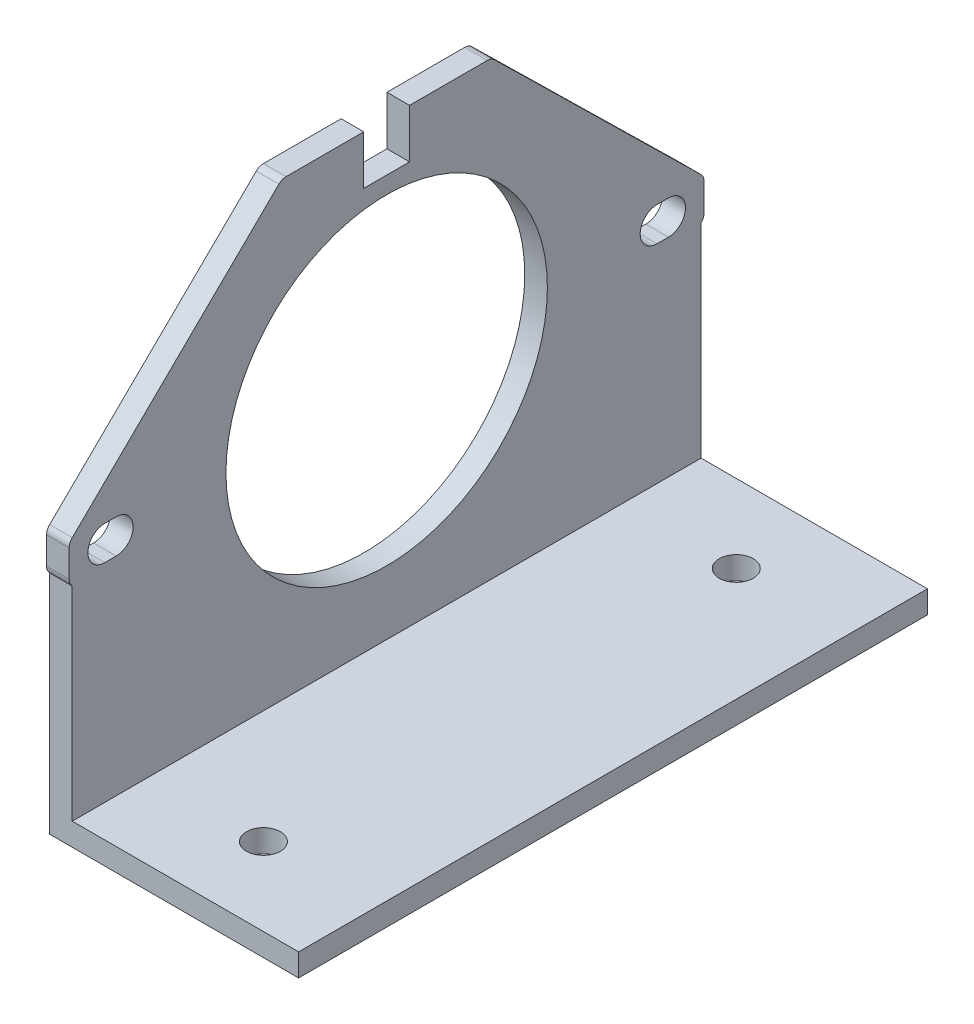
from build123d import *

# Parameters (mm, degrees)
SKETCH1_R           = 14.2
SKETCH1_W           = 4.4
SKETCH1_H           = 4.2
BOSS_EXTRUDE1_DEPTH = 2
BOSS_EXTRUDE2_DEPTH = 2
SKETCH3_W           = 55.560809748
SKETCH3_H           = 2
BOSS_EXTRUDE3_DEPTH = 20
CUT_EXTRUDE1_DEPTH  = 2


with BuildPart() as part:
    # Sketch1 → Boss-Extrude1 (new body)
    with BuildSketch(Plane(origin=(668.139739498, 0, 0), x_dir=(0, 0, -1), z_dir=(1, 0, 0))):
        with BuildLine():
            ThreePointArc((-1314.332175016, 878.774707493), (-1314.042285701, 878.583942821), (-1313.701770142, 878.517038946))
            Line((-1313.701770142, 878.517038946), (-1306.83550516, 878.517038946))
            Line((-1306.83550516, 878.517038946), (-1306.83550516, 882.842038946))
            Line((-1306.83550516, 882.842038946), (-1302.78550516, 882.842038946))
            Line((-1302.78550516, 882.842038946), (-1302.78550516, 878.517038946))
            Line((-1302.78550516, 878.517038946), (-1295.919240178, 878.517038946))
            ThreePointArc((-1295.919240178, 878.517038946), (-1295.578724618, 878.583942821), (-1295.288835304, 878.774707493))
            Line((-1295.288835304, 878.774707493), (-1277.030100286, 896.694420906))
            ThreePointArc((-1277.030100286, 896.694420906), (-1276.830636379, 896.988445301), (-1276.76050516, 897.336752359))
            Line((-1276.76050516, 897.336752359), (-1276.76050516, 899.747325533))
            ThreePointArc((-1276.76050516, 899.747325533), (-1276.830636379, 900.095632591), (-1277.030100286, 900.389656986))
            Line((-1277.030100286, 900.389656986), (-1295.288835304, 918.309370399))
            ThreePointArc((-1295.288835304, 918.309370399), (-1295.578724618, 918.500135071), (-1295.919240178, 918.567038946))
            Line((-1295.919240178, 918.567038946), (-1302.78550516, 918.567038946))
            Line((-1302.78550516, 918.567038946), (-1302.78550516, 914.242038946))
            Line((-1302.78550516, 914.242038946), (-1306.83550516, 914.242038946))
            Line((-1306.83550516, 914.242038946), (-1306.83550516, 918.567038946))
            Line((-1306.83550516, 918.567038946), (-1313.701770142, 918.567038946))
            ThreePointArc((-1313.701770142, 918.567038946), (-1314.042285701, 918.500135071), (-1314.332175016, 918.309370399))
            Line((-1314.332175016, 918.309370399), (-1332.590910034, 900.389656986))
            ThreePointArc((-1332.590910034, 900.389656986), (-1332.79037394, 900.095632591), (-1332.86050516, 899.747325533))
            Line((-1332.86050516, 899.747325533), (-1332.86050516, 897.336752359))
            ThreePointArc((-1332.86050516, 897.336752359), (-1332.79037394, 896.988445301), (-1332.590910034, 896.694420906))
            Line((-1332.590910034, 896.694420906), (-1314.332175016, 878.774707493))
        make_face()
        with Locations((-1304.81050516, 898.542038946)):
            Circle(SKETCH1_R, mode=Mode.SUBTRACT)
        with BuildLine():
            Line((-1329.71050516, 900.042038946), (-1328.71050516, 900.042038946))
            ThreePointArc((-1328.71050516, 900.042038946), (-1327.21050516, 898.542038946), (-1328.71050516, 897.042038946))
            Line((-1328.71050516, 897.042038946), (-1329.71050516, 897.042038946))
            ThreePointArc((-1329.71050516, 897.042038946), (-1330.771165332, 897.481378774), (-1331.21050516, 898.542038946))
            ThreePointArc((-1331.21050516, 898.542038946), (-1330.771165332, 899.602699118), (-1329.71050516, 900.042038946))
        make_face(mode=Mode.SUBTRACT)
        with BuildLine():
            ThreePointArc((-1279.91050516, 900.042038946), (-1278.41050516, 898.542038946), (-1279.91050516, 897.042038946))
            Line((-1279.91050516, 897.042038946), (-1280.91050516, 897.042038946))
            ThreePointArc((-1280.91050516, 897.042038946), (-1281.971165332, 897.481378774), (-1282.41050516, 898.542038946))
            ThreePointArc((-1282.41050516, 898.542038946), (-1281.971165332, 899.602699118), (-1280.91050516, 900.042038946))
            Line((-1280.91050516, 900.042038946), (-1279.91050516, 900.042038946))
        make_face(mode=Mode.SUBTRACT)
        with Locations((-1286.76050516, 898.542038946)):
            Rectangle(SKETCH1_W, SKETCH1_H, mode=Mode.SUBTRACT)
        with Locations((-1322.86050516, 898.542038946)):
            Rectangle(SKETCH1_W, SKETCH1_H, mode=Mode.SUBTRACT)
        with Locations((-1322.86050516, 898.542038946)):
            Rectangle(SKETCH1_W, SKETCH1_H)
        with Locations((-1286.76050516, 898.542038946)):
            Rectangle(SKETCH1_W, SKETCH1_H)
    extrude(amount=BOSS_EXTRUDE1_DEPTH)

    # Sketch2 → Boss-Extrude2 (add)
    with BuildSketch(Plane(origin=(670.139739498, 0, 0), x_dir=(0, 0, -1), z_dir=(1, 0, 0))):
        with BuildLine():
            Line((-1332.590910034, 876.694420906), (-1277.030100286, 876.694420906))
            Line((-1277.030100286, 876.694420906), (-1277.030100286, 896.694420906))
            Line((-1277.030100286, 896.694420906), (-1295.288835304, 878.774707493))
            ThreePointArc((-1295.288835304, 878.774707493), (-1295.578724618, 878.583942821), (-1295.919240178, 878.517038946))
            Line((-1295.919240178, 878.517038946), (-1302.78550516, 878.517038946))
            Line((-1302.78550516, 878.517038946), (-1302.78550516, 882.842038946))
            Line((-1302.78550516, 882.842038946), (-1306.83550516, 882.842038946))
            Line((-1306.83550516, 882.842038946), (-1306.83550516, 878.517038946))
            Line((-1306.83550516, 878.517038946), (-1313.701770142, 878.517038946))
            ThreePointArc((-1313.701770142, 878.517038946), (-1314.042285701, 878.583942821), (-1314.332175016, 878.774707493))
            Line((-1314.332175016, 878.774707493), (-1332.590910034, 896.694420906))
            Line((-1332.590910034, 896.694420906), (-1332.590910034, 876.694420906))
        make_face()
    extrude(amount=-BOSS_EXTRUDE2_DEPTH)

    # Sketch3 → Boss-Extrude3 (add)
    with BuildSketch(Plane(origin=(670.139739498, 0, 0), x_dir=(0, 0, -1), z_dir=(1, 0, 0))):
        with Locations((-1304.81050516, 877.694420906)):
            Rectangle(SKETCH3_W, SKETCH3_H)
    extrude(amount=BOSS_EXTRUDE3_DEPTH)

    # Sketch4 → Cut-Extrude1 (cut)
    with BuildSketch(Plane(origin=(0, 878.694420906, 0), x_dir=(1, 0, 0), z_dir=(0, 1, 0))):
        with BuildLine():
            ThreePointArc((681.639739498, -1283.920302723), (681.20039967, -1282.859642551), (680.139739498, -1282.420302723))
            Line((680.139739498, -1282.420302723), (680.139739498, -1285.420302723))
            ThreePointArc((680.139739498, -1285.420302723), (681.20039967, -1284.980962895), (681.639739498, -1283.920302723))
        make_face()
        with BuildLine():
            Line((680.139739498, -1285.420302723), (680.139739498, -1282.420302723))
            ThreePointArc((680.139739498, -1282.420302723), (678.639739498, -1283.920302723), (680.139739498, -1285.420302723))
        make_face()
        with BuildLine():
            ThreePointArc((681.639739498, -1325.700707597), (681.20039967, -1324.640047425), (680.139739498, -1324.200707597))
            Line((680.139739498, -1324.200707597), (680.139739498, -1327.200707597))
            ThreePointArc((680.139739498, -1327.200707597), (681.20039967, -1326.761367768), (681.639739498, -1325.700707597))
        make_face()
        with BuildLine():
            Line((680.139739498, -1327.200707597), (680.139739498, -1324.200707597))
            ThreePointArc((680.139739498, -1324.200707597), (678.639739498, -1325.700707597), (680.139739498, -1327.200707597))
        make_face()
    extrude(amount=-CUT_EXTRUDE1_DEPTH, mode=Mode.SUBTRACT)


solid = part.part
